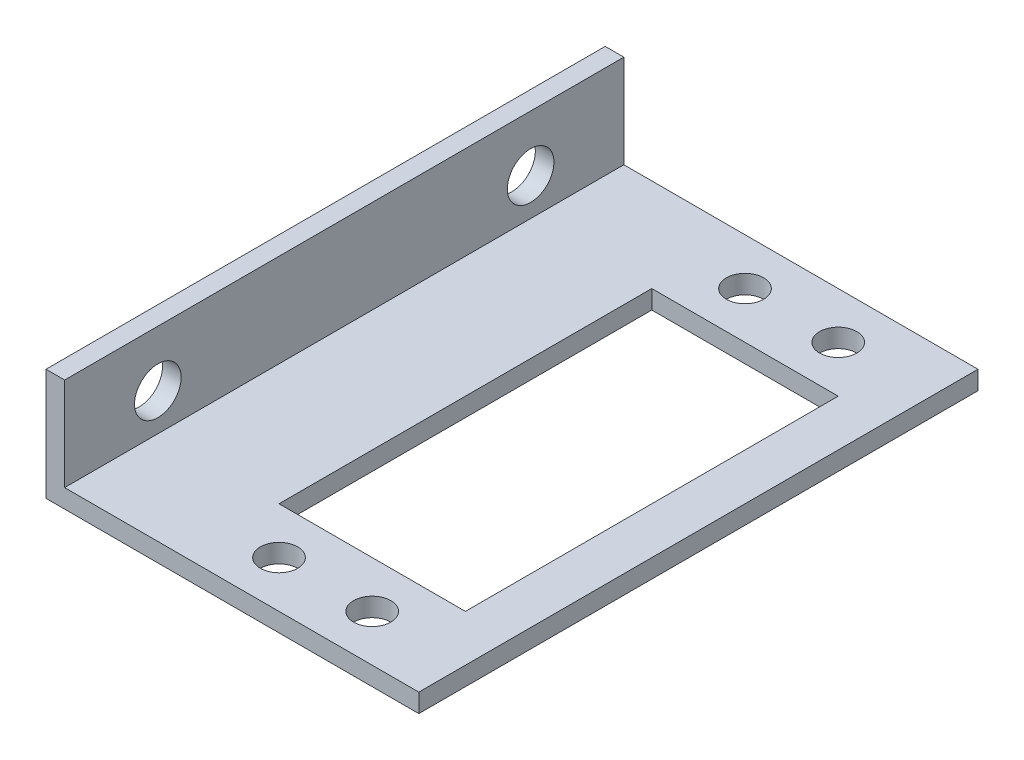
from build123d import *

# Parameters (mm, degrees)
SALIENTE_EXTRUIR1_DEPTH = 60
CROQUIS3_R              = 2.5
CORTAR_EXTRUIR1_DEPTH   = 60
CROQUIS4_R              = 2
CROQUIS4_W              = 20
CROQUIS4_H              = 40
CORTAR_EXTRUIR2_DEPTH   = 60


with BuildPart() as part:
    # Croquis2 → Saliente-Extruir1 (new body)
    with BuildSketch(Plane.XY):
        Polygon((-27.386914876, 0), (12.613085124, 0), (12.613085124, 2), (-25.386914876, 2), (-25.386914876, 12), (-27.386914876, 12), align=None)
    extrude(amount=SALIENTE_EXTRUIR1_DEPTH)

    # Croquis3 → Cortar-Extruir1 (cut)
    with BuildSketch(Plane.ZY.offset(27.386914876)):
        with Locations((10, 6)):
            Circle(CROQUIS3_R)
        with Locations((50, 6)):
            Circle(CROQUIS3_R)
    extrude(amount=-CORTAR_EXTRUIR1_DEPTH, mode=Mode.SUBTRACT)

    # Croquis4 → Cortar-Extruir2 (cut)
    with BuildSketch(Plane.XZ):
        with Locations((-7.386914876, 55)):
            Circle(CROQUIS4_R)
        with Locations((2.613085124, 55)):
            Circle(CROQUIS4_R)
        with Locations((-7.386914876, 5)):
            Circle(CROQUIS4_R)
        with Locations((2.613085124, 5)):
            Circle(CROQUIS4_R)
        with Locations((-2.386914876, 30)):
            Rectangle(CROQUIS4_W, CROQUIS4_H)
    extrude(amount=-CORTAR_EXTRUIR2_DEPTH, mode=Mode.SUBTRACT)


solid = part.part
